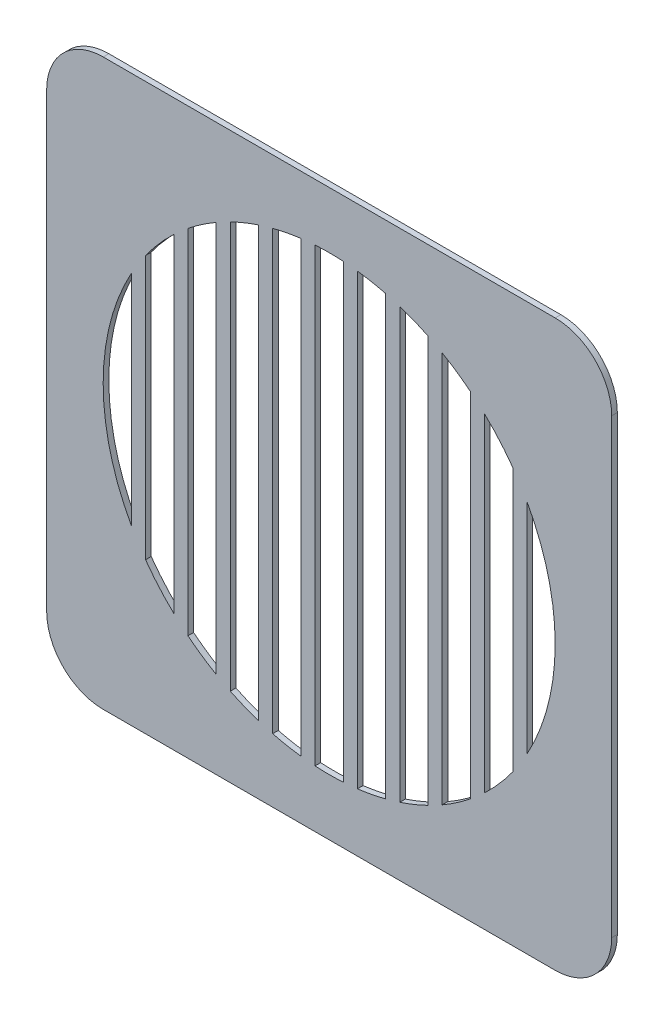
from build123d import *

# Parameters (mm, degrees)
SKETCH1_R           = 40
BOSS_EXTRUDE1_DEPTH = 1
SKETCH3_W           = 2.5
SKETCH3_H           = 80
BOSS_EXTRUDE2_DEPTH = 1


with BuildPart() as part:
    # Sketch1 → Boss-Extrude1 (new body)
    with BuildSketch(Plane.XY):
        with BuildLine():
            Line((-40, 50), (40, 50))
            ThreePointArc((40, 50), (47.071067812, 47.071067812), (50, 40))
            Line((50, 40), (50, -40))
            ThreePointArc((50, -40), (47.071067812, -47.071067812), (40, -50))
            Line((40, -50), (-40, -50))
            ThreePointArc((-40, -50), (-47.071067812, -47.071067812), (-50, -40))
            Line((-50, -40), (-50, 40))
            ThreePointArc((-50, 40), (-47.071067812, 47.071067812), (-40, 50))
        make_face()
        Circle(SKETCH1_R, mode=Mode.SUBTRACT)
    extrude(amount=BOSS_EXTRUDE1_DEPTH)

    # Sketch3 → Boss-Extrude2 (add)
    with BuildSketch(Plane.XY.offset(1)):
        with Locations((-33.75, 0)):
            Rectangle(SKETCH3_W, SKETCH3_H)
        with Locations((-26.25, 0)):
            Rectangle(SKETCH3_W, SKETCH3_H)
        with Locations((-18.75, 0)):
            Rectangle(SKETCH3_W, SKETCH3_H)
        with Locations((-11.25, 0)):
            Rectangle(SKETCH3_W, SKETCH3_H)
        with Locations((-3.75, 0)):
            Rectangle(SKETCH3_W, SKETCH3_H)
        with Locations((3.75, 0)):
            Rectangle(SKETCH3_W, SKETCH3_H)
        with Locations((11.25, 0)):
            Rectangle(SKETCH3_W, SKETCH3_H)
        with Locations((18.75, 0)):
            Rectangle(SKETCH3_W, SKETCH3_H)
        with Locations((26.25, 0)):
            Rectangle(SKETCH3_W, SKETCH3_H)
        with Locations((33.75, 0)):
            Rectangle(SKETCH3_W, SKETCH3_H)
    extrude(amount=-BOSS_EXTRUDE2_DEPTH)


solid = part.part
